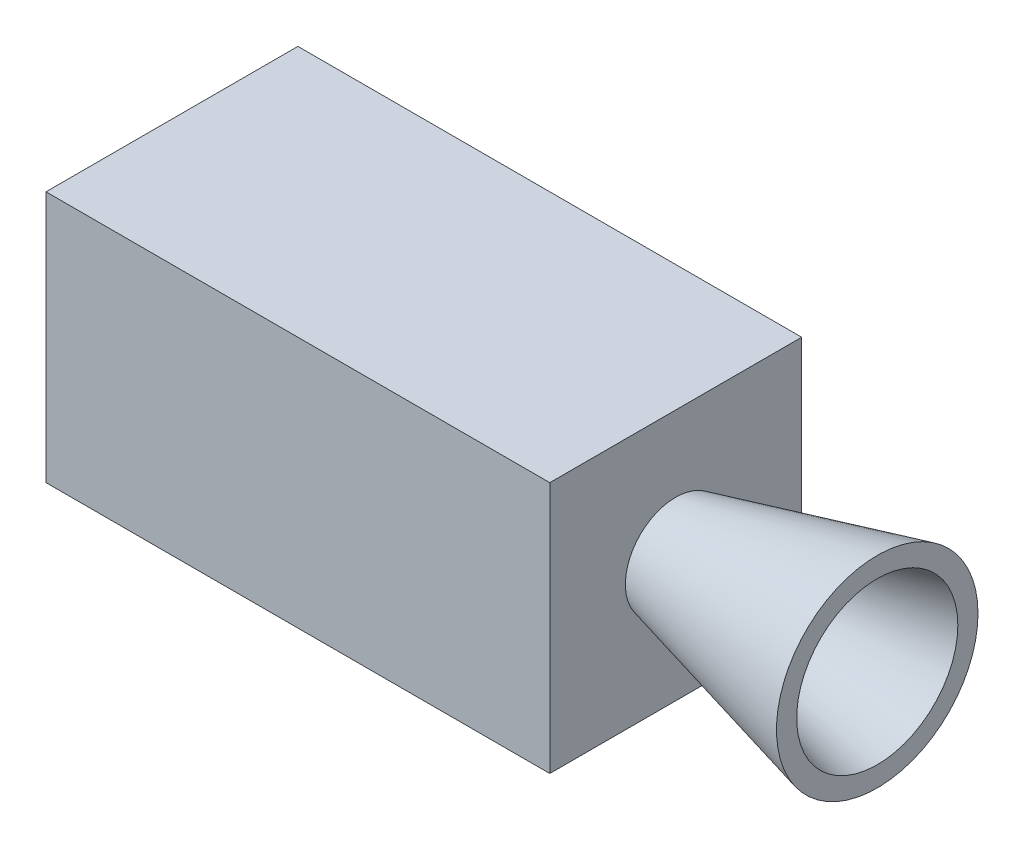
from build123d import *

# Parameters (mm, degrees)
BOSS_EXTRUDE1_DEPTH      = 250
BOSS_EXTRUDE1_DEPTH_BACK = 250
SKETCH1_W                = 1000
SKETCH1_H                = 500


with BuildPart() as part:
    # Sketch1 → Boss-Extrude1 (new, two sides: drawn at the far end of the back side and taken through both)
    with BuildSketch(Plane.XY.offset(-BOSS_EXTRUDE1_DEPTH_BACK)):
        with Locations((500, 0)):
            Rectangle(SKETCH1_W, SKETCH1_H)
    extrude(amount=BOSS_EXTRUDE1_DEPTH + BOSS_EXTRUDE1_DEPTH_BACK)

    # Sketch3 → Revolve1 (revolve)
    with BuildSketch(Plane.XY):
        Polygon((1000, 0), (1000, 100), (1400, 200), (1400, 160), (1040, 70), (1040, 0), align=None)
    revolve(axis=Axis((1040, 0, 0), (-1, 0, 0)))


solid = part.part
